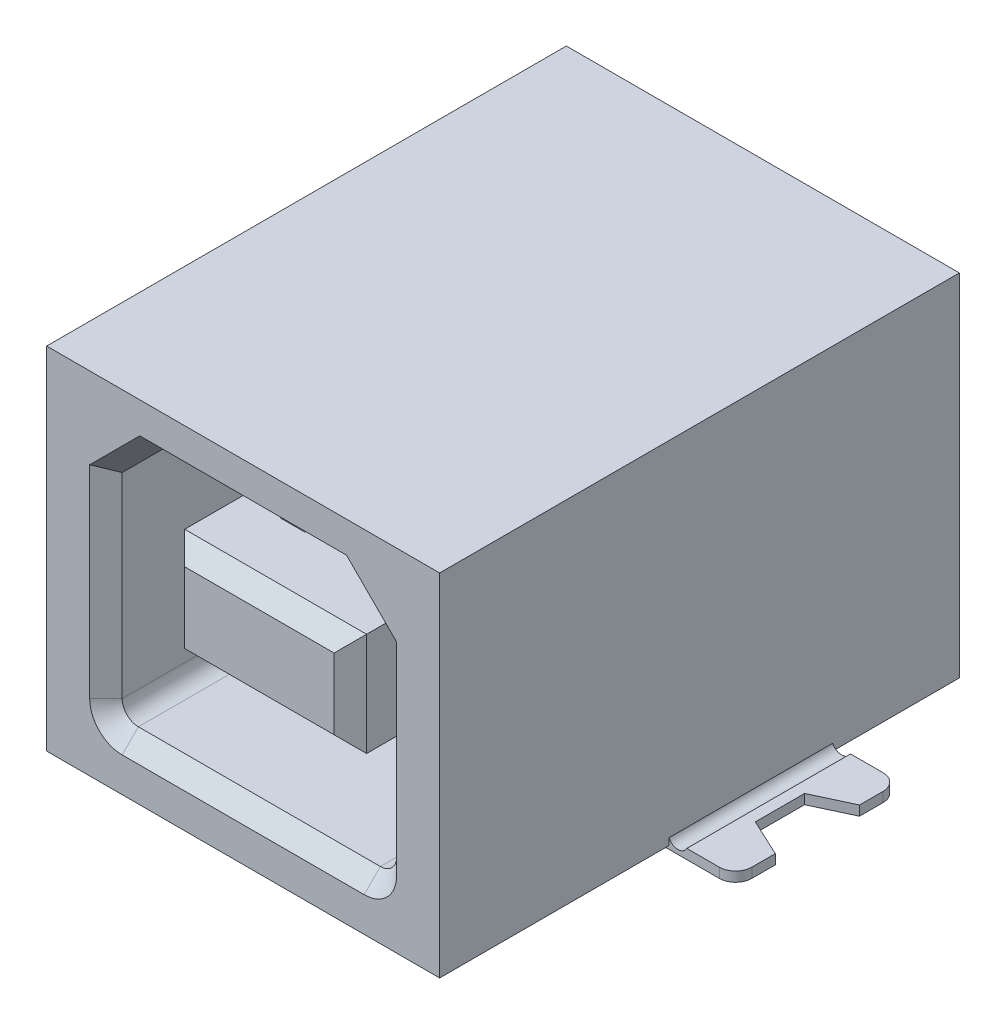
from build123d import *

# Parameters (mm, degrees)
SKETCH1_W                    = 12.1
SKETCH1_H                    = 10.8
BASE_DEPTH                   = 8
CONTACT_OPENING_DEPTH        = 9
CONTACT_OPENING_LEAD_IN_SIZE = 0.5
SKETCH3_W                    = 5.6
SKETCH3_H                    = 3.18
CONTACT_AREA_DEPTH           = 8.5
CONTACT_AREA_LEAD_IN_SIZE    = 0.5
GROUND_LEGS_DEPTH            = 2.52
GROUND_LEGS_SHAPE_DEPTH      = 0.3
SM_TAILS_DEPTH               = 0.3
CONTACT_DEPTH                = 0.375
CONTACT_PATTERN_COUNT        = 2
CONTACT_PATTERN_PITCH        = 2.5
LPATTERN1_COUNT              = 2
LPATTERN1_PITCH              = 1.25
LPATTERN1_COL_COUNT          = 3
LPATTERN1_COL_PITCH          = 1.25
SKETCH12_R                   = 0.575
ALIGNMENT_PIN_DEPTH          = 1.9
PIN_POINT_SIZE               = 0.05


with BuildPart() as part:
    # Sketch1 → Base (new body, symmetric)
    with BuildSketch(Plane.XY):
        Rectangle(SKETCH1_W, SKETCH1_H)
    extrude(amount=BASE_DEPTH, both=True)

    # Sketch2 → Contact Opening (cut)
    with BuildSketch(Plane.XY.offset(8)):
        with BuildLine():
            Line((-2.975, 3.94), (-4.225, 2.69))
            Line((-4.225, 2.69), (-4.225, -3.34))
            ThreePointArc((-4.225, -3.34), (-4.078553391, -3.693553391), (-3.725, -3.84))
            Line((-3.725, -3.84), (3.725, -3.84))
            ThreePointArc((3.725, -3.84), (4.078553391, -3.693553391), (4.225, -3.34))
            Line((4.225, -3.34), (4.225, 2.69))
            Line((4.225, 2.69), (2.975, 3.94))
            Line((2.975, 3.94), (-2.975, 3.94))
        make_face()
    extrude(amount=-CONTACT_OPENING_DEPTH, mode=Mode.SUBTRACT)

    # Contact Opening Lead-in
    contact_opening_lead_in_edges = [part.edges().sort_by_distance(p)[0] for p in [
        (0, 3.94, 8),
        (-3.6, 3.315, 8),
        (-4.225, -0.325, 8),
        (-4.078553391, -3.693553391, 8),
        (0, -3.84, 8),
        (4.078553391, -3.693553391, 8),
        (4.225, -0.325, 8),
        (3.6, 3.315, 8),
    ]]
    chamfer(contact_opening_lead_in_edges, length=CONTACT_OPENING_LEAD_IN_SIZE)

    # Sketch3 → Contact Area (add)
    with BuildSketch(Plane.XY.offset(-1)):
        with Locations((0, 0.05)):
            Rectangle(SKETCH3_W, SKETCH3_H)
    extrude(amount=CONTACT_AREA_DEPTH)

    # Contact Area Lead-in
    contact_area_lead_in_edges = [part.edges().sort_by_distance(p)[0] for p in [
        (-2.8, 0.05, 7.5),
        (0, -1.54, 7.5),
        (2.8, 0.05, 7.5),
        (0, 1.64, 7.5),
    ]]
    chamfer(contact_area_lead_in_edges, length=CONTACT_AREA_LEAD_IN_SIZE)

    # Sketch4 → Ground Legs (add, symmetric)
    with BuildSketch(Plane.XY.offset(-1.58)):
        with BuildLine():
            Line((6.02, -5.058034034), (5.72, -5.100661668))
            ThreePointArc((5.72, -5.100661668), (5.776842077, -5.318050295), (5.90868722, -5.5))
            Line((5.90868722, -5.5), (8.1, -5.5))
            Line((8.1, -5.5), (8.1, -5.2))
            Line((8.1, -5.2), (6.599504335, -5.2))
            ThreePointArc((6.599504335, -5.2), (6.254059507, -5.356354169), (6.02, -5.058034034))
        make_face()
        with BuildLine():
            Line((-5.90868722, -5.5), (-8.1, -5.5))
            Line((-8.1, -5.5), (-8.1, -5.2))
            Line((-8.1, -5.2), (-6.599504335, -5.2))
            ThreePointArc((-6.599504335, -5.2), (-6.254059507, -5.356354169), (-6.02, -5.058034034))
            Line((-6.02, -5.058034034), (-5.72, -5.100661668))
            ThreePointArc((-5.72, -5.100661668), (-5.776842077, -5.318050295), (-5.90868722, -5.5))
        make_face()
    extrude(amount=GROUND_LEGS_DEPTH, both=True)

    # Sketch9 → ground legs shape (cut)
    with BuildSketch(Plane(origin=(0, -5.2, 0), x_dir=(-1, 0, 0), z_dir=(0, 1, 0))):
        with BuildLine():
            Line((-8.1, -4.1), (-8.1, -3.6))
            ThreePointArc((-8.1, -3.6), (-7.953553391, -3.953553391), (-7.6, -4.1))
            Line((-7.6, -4.1), (-8.1, -4.1))
        make_face()
        Polygon((-8.1, -2.875946044), (-6.946732983, -2.33830257), (-6.946732983, -0.82169743), (-8.1, -0.284053956), align=None)
        with BuildLine():
            Line((-8.1, 0.94), (-7.6, 0.94))
            ThreePointArc((-7.6, 0.94), (-7.953553391, 0.793553391), (-8.1, 0.44))
            Line((-8.1, 0.44), (-8.1, 0.94))
        make_face()
        with BuildLine():
            Line((8.1, 0.94), (8.1, 0.44))
            ThreePointArc((8.1, 0.44), (7.953553391, 0.793553391), (7.6, 0.94))
            Line((7.6, 0.94), (8.1, 0.94))
        make_face()
        Polygon((8.1, -0.284053956), (6.946732983, -0.82169743), (6.946732983, -2.33830257), (8.1, -2.875946044), align=None)
        with BuildLine():
            Line((8.1, -4.1), (7.6, -4.1))
            ThreePointArc((7.6, -4.1), (7.953553391, -3.953553391), (8.1, -3.6))
            Line((8.1, -3.6), (8.1, -4.1))
        make_face()
    extrude(amount=-GROUND_LEGS_SHAPE_DEPTH, mode=Mode.SUBTRACT)

    # Sketch11 → SM Tails (add, symmetric)
    with BuildSketch(Plane(origin=(0.75, 0, 0), x_dir=(0, 0, -1), z_dir=(1, 0, 0))):
        with BuildLine():
            Line((7.15, -5.3), (7.15, -5.15))
            Line((7.15, -5.15), (7.4, -5.15))
            ThreePointArc((7.4, -5.15), (7.429289322, -5.220710678), (7.5, -5.25))
            Line((7.5, -5.25), (9.15, -5.25))
            Line((9.15, -5.25), (9.15, -5.5))
            Line((9.15, -5.5), (7.35, -5.5))
            ThreePointArc((7.35, -5.5), (7.208578644, -5.441421356), (7.15, -5.3))
        make_face()
    sm_tails = extrude(amount=SM_TAILS_DEPTH, both=True)

    # Sketch8 → Contact (add, symmetric)
    with BuildSketch(Plane(origin=(-1.25, 0, 0), x_dir=(0, 0, -1), z_dir=(1, 0, 0))):
        with BuildLine():
            Line((1, 1.64), (-2.511141434, 2.21990157))
            ThreePointArc((-2.511141434, 2.21990157), (-3.280012008, 2.246903627), (-4.030467404, 2.077469952))
            Line((-4.030467404, 2.077469952), (-5.5, 1.54))
            Line((-5.5, 1.54), (-5.439889401, 1.375647586))
            Line((-5.439889401, 1.375647586), (-3.970356805, 1.913117538))
            ThreePointArc((-3.970356805, 1.913117538), (-3.263677974, 2.072667582), (-2.539658184, 2.047240645))
            Line((-2.539658184, 2.047240645), (0.97148325, 1.467339075))
            Line((0.97148325, 1.467339075), (1, 1.64))
        make_face()
        with BuildLine():
            Line((-5.439889401, -1.275647586), (-5.5, -1.44))
            Line((-5.5, -1.44), (-4.030467404, -1.977469952))
            ThreePointArc((-4.030467404, -1.977469952), (-3.280012008, -2.146903627), (-2.511141434, -2.11990157))
            Line((-2.511141434, -2.11990157), (1, -1.54))
            Line((1, -1.54), (0.97148325, -1.367339075))
            Line((0.97148325, -1.367339075), (-2.539658184, -1.947240645))
            ThreePointArc((-2.539658184, -1.947240645), (-3.263677974, -1.972667582), (-3.970356805, -1.813117538))
            Line((-3.970356805, -1.813117538), (-5.439889401, -1.275647586))
        make_face()
    contact = extrude(amount=CONTACT_DEPTH, both=True)

    # Contact Pattern: Contact ×2
    with Locations(*[(i * CONTACT_PATTERN_PITCH, 0, 0) for i in range(1, CONTACT_PATTERN_COUNT)]):
        add(contact)

    # LPattern1: SM Tails ×2
    with Locations(*[(i * LPATTERN1_PITCH, 0, 0) for i in range(1, LPATTERN1_COUNT)]):
        add(sm_tails)

    # LPattern1 col: SM Tails ×3
    with Locations(*[(-i * LPATTERN1_COL_PITCH, 0, 0) for i in range(1, LPATTERN1_COL_COUNT)]):
        add(sm_tails)

    # Sketch12 → Alignment Pin (add)
    with BuildSketch(Plane.XZ.offset(5.4)):
        with Locations((2.75, -1)):
            Circle(SKETCH12_R)
        with Locations((-2.75, -1)):
            Circle(SKETCH12_R)
    extrude(amount=ALIGNMENT_PIN_DEPTH)

    # Pin Point
    pin_point_edges = [part.edges().sort_by_distance(p)[0] for p in [
        (2.175, -7.3, -1),
        (-3.325, -7.3, -1),
    ]]
    chamfer(pin_point_edges, length=PIN_POINT_SIZE)


solid = part.part
